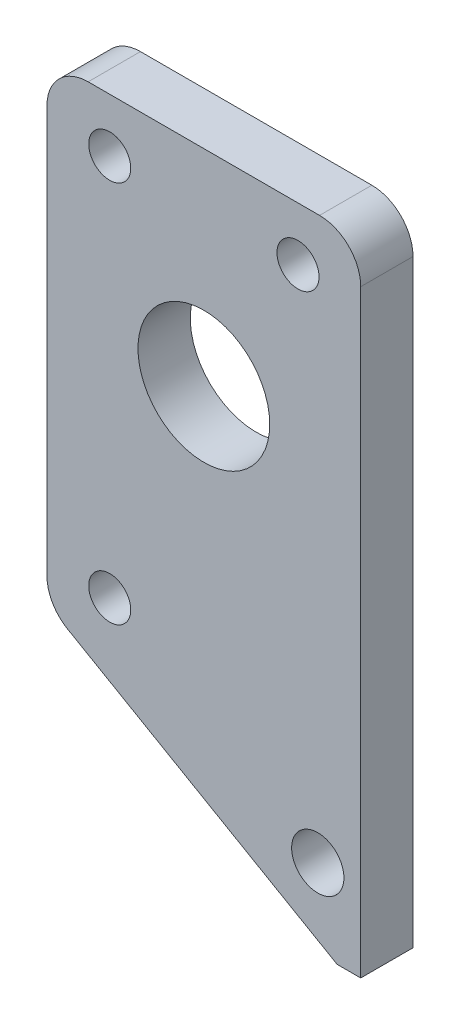
from build123d import *

# Parameters (mm, degrees)
SKETCH1_R                   = 3.175
SKETCH1_R_2                 = 8
BOSS_EXTRUDE1_DEPTH         = 6.35
FILLET1_R                   = 5
F_1_4_20_TAPPED_HOLE1_D     = 5.1054
F_1_4_20_TAPPED_HOLE1_DEPTH = 19.05
F_1_4_20_TAPPED_HOLE1_TIP   = 1.533816902


with BuildPart() as part:
    # Sketch1 → Boss-Extrude1 (new body)
    with BuildSketch(Plane.XY):
        Polygon((16.184070214, -255.902577388), (-19.05, -235.560177465), (-19.05, -178.2), (19.05, -178.2), (19.05, -255.902577388), align=None)
        with Locations((13.834070214, -246.4)):
            Circle(SKETCH1_R, mode=Mode.SUBTRACT)
        with Locations((0, -203.2)):
            Circle(SKETCH1_R_2, mode=Mode.SUBTRACT)
    extrude(amount=BOSS_EXTRUDE1_DEPTH)

    # Fillet1
    fillet1_edges = [part.edges().sort_by_distance(p)[0] for p in [
        (-19.05, -235.560177465, 3.175),
        (-19.05, -178.2, 3.175),
        (19.05, -178.2, 3.175),
    ]]
    fillet(fillet1_edges, radius=FILLET1_R)

    # 1_4-20 Tapped Hole1
    with Locations(Plane.XY.offset(6.35)):
        with Locations((-11.43, -184.7), (-11.43, -231.16), (11.43, -184.7)):
            Hole(F_1_4_20_TAPPED_HOLE1_D / 2, depth=F_1_4_20_TAPPED_HOLE1_DEPTH)
            with Locations((0, 0, -(F_1_4_20_TAPPED_HOLE1_DEPTH + F_1_4_20_TAPPED_HOLE1_TIP / 2))):  # 118° drill point
                Cone(0, F_1_4_20_TAPPED_HOLE1_D / 2, F_1_4_20_TAPPED_HOLE1_TIP, mode=Mode.SUBTRACT)


solid = part.part
